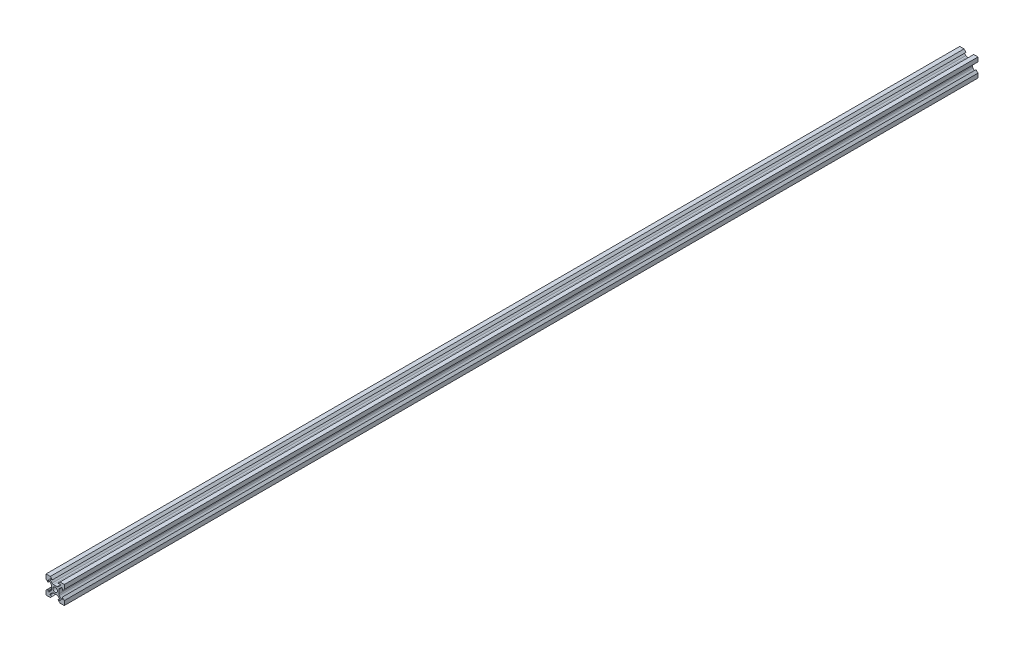
from build123d import *

# Parameters (mm, degrees)
SKETCH1_R           = 2.5
BOSS_EXTRUDE2_DEPTH = 1000


with BuildPart() as part:
    # Sketch1 → Boss-Extrude2 (new body)
    with BuildSketch(Plane.XY):
        with BuildLine():
            Line((-4, 0), (-4, 1.898780669))
            ThreePointArc((-4, 1.898780669), (-4.152240935, 2.664147534), (-4.585786438, 3.312994231))
            Line((-4.585786438, 3.312994231), (-6.826345597, 5.553553391))
            ThreePointArc((-6.826345597, 5.553553391), (-6.988557271, 5.661939766), (-7.179898987, 5.7))
            Line((-7.179898987, 5.7), (-7.3, 5.7))
            ThreePointArc((-7.3, 5.7), (-7.653553391, 5.553553391), (-7.8, 5.2))
            Line((-7.8, 5.2), (-7.8, 3.1))
            Line((-7.8, 3.1), (-10, 5.3))
            Line((-10, 5.3), (-10, 10))
            Line((-10, 10), (-5.3, 10))
            Line((-5.3, 10), (-3.1, 7.8))
            Line((-3.1, 7.8), (-5.2, 7.8))
            ThreePointArc((-5.2, 7.8), (-5.553553391, 7.653553391), (-5.7, 7.3))
            Line((-5.7, 7.3), (-5.7, 7.179898987))
            ThreePointArc((-5.7, 7.179898987), (-5.661939766, 6.988557271), (-5.553553391, 6.826345597))
            Line((-5.553553391, 6.826345597), (-3.312994231, 4.585786438))
            ThreePointArc((-3.312994231, 4.585786438), (-2.664147534, 4.152240935), (-1.898780669, 4))
            Line((-1.898780669, 4), (0, 4))
            Line((0, 4), (1.898780669, 4))
            ThreePointArc((1.898780669, 4), (2.664147534, 4.152240935), (3.312994231, 4.585786438))
            Line((3.312994231, 4.585786438), (5.553553391, 6.826345597))
            ThreePointArc((5.553553391, 6.826345597), (5.661939766, 6.988557271), (5.7, 7.179898987))
            Line((5.7, 7.179898987), (5.7, 7.3))
            ThreePointArc((5.7, 7.3), (5.553553391, 7.653553391), (5.2, 7.8))
            Line((5.2, 7.8), (3.1, 7.8))
            Line((3.1, 7.8), (5.3, 10))
            Line((5.3, 10), (10, 10))
            Line((10, 10), (10, 5.3))
            Line((10, 5.3), (7.8, 3.1))
            Line((7.8, 3.1), (7.8, 5.2))
            ThreePointArc((7.8, 5.2), (7.653553391, 5.553553391), (7.3, 5.7))
            Line((7.3, 5.7), (7.179898987, 5.7))
            ThreePointArc((7.179898987, 5.7), (6.988557271, 5.661939766), (6.826345597, 5.553553391))
            Line((6.826345597, 5.553553391), (4.585786438, 3.312994231))
            ThreePointArc((4.585786438, 3.312994231), (4.152240935, 2.664147534), (4, 1.898780669))
            Line((4, 1.898780669), (4, 0))
            Line((4, 0), (4, -1.898780669))
            ThreePointArc((4, -1.898780669), (4.152240935, -2.664147534), (4.585786438, -3.312994231))
            Line((4.585786438, -3.312994231), (6.826345597, -5.553553391))
            ThreePointArc((6.826345597, -5.553553391), (6.988557271, -5.661939766), (7.179898987, -5.7))
            Line((7.179898987, -5.7), (7.3, -5.7))
            ThreePointArc((7.3, -5.7), (7.653553391, -5.553553391), (7.8, -5.2))
            Line((7.8, -5.2), (7.8, -3.1))
            Line((7.8, -3.1), (10, -5.3))
            Line((10, -5.3), (10, -10))
            Line((10, -10), (5.3, -10))
            Line((5.3, -10), (3.1, -7.8))
            Line((3.1, -7.8), (5.2, -7.8))
            ThreePointArc((5.2, -7.8), (5.553553391, -7.653553391), (5.7, -7.3))
            Line((5.7, -7.3), (5.7, -7.179898987))
            ThreePointArc((5.7, -7.179898987), (5.661939766, -6.988557271), (5.553553391, -6.826345597))
            Line((5.553553391, -6.826345597), (3.312994231, -4.585786438))
            ThreePointArc((3.312994231, -4.585786438), (2.664147534, -4.152240935), (1.898780669, -4))
            Line((1.898780669, -4), (0, -4))
            Line((0, -4), (-1.898780669, -4))
            ThreePointArc((-1.898780669, -4), (-2.664147534, -4.152240935), (-3.312994231, -4.585786438))
            Line((-3.312994231, -4.585786438), (-5.553553391, -6.826345597))
            ThreePointArc((-5.553553391, -6.826345597), (-5.661939766, -6.988557271), (-5.7, -7.179898987))
            Line((-5.7, -7.179898987), (-5.7, -7.3))
            ThreePointArc((-5.7, -7.3), (-5.553553391, -7.653553391), (-5.2, -7.8))
            Line((-5.2, -7.8), (-3.1, -7.8))
            Line((-3.1, -7.8), (-5.3, -10))
            Line((-5.3, -10), (-10, -10))
            Line((-10, -10), (-10, -5.3))
            Line((-10, -5.3), (-7.8, -3.1))
            Line((-7.8, -3.1), (-7.8, -5.2))
            ThreePointArc((-7.8, -5.2), (-7.653553391, -5.553553391), (-7.3, -5.7))
            Line((-7.3, -5.7), (-7.179898987, -5.7))
            ThreePointArc((-7.179898987, -5.7), (-6.988557271, -5.661939766), (-6.826345597, -5.553553391))
            Line((-6.826345597, -5.553553391), (-4.585786438, -3.312994231))
            ThreePointArc((-4.585786438, -3.312994231), (-4.152240935, -2.664147534), (-4, -1.898780669))
            Line((-4, -1.898780669), (-4, 0))
        make_face()
        Circle(SKETCH1_R, mode=Mode.SUBTRACT)
    extrude(amount=BOSS_EXTRUDE2_DEPTH)


solid = part.part
